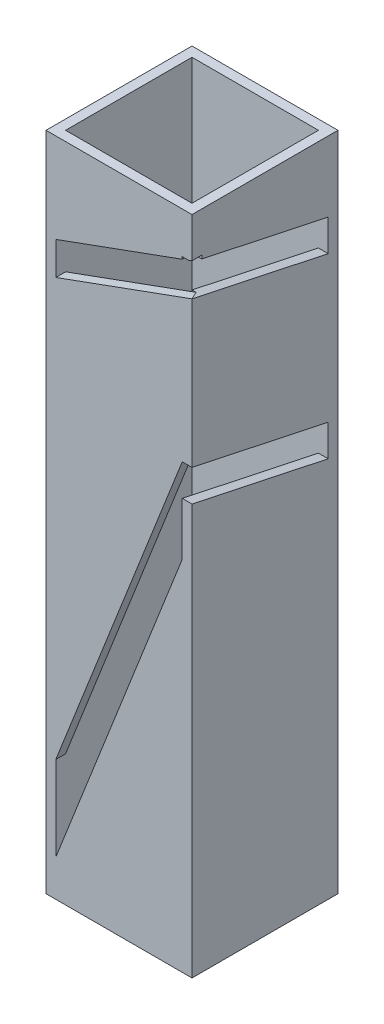
from build123d import *

# Parameters (mm, degrees)
SKETCH1_W           = 44.862
SKETCH1_H           = 44.862
SKETCH1_W_2         = 38.862
SKETCH1_H_2         = 38.862
BOSS_EXTRUDE1_DEPTH = 203.2
X_FACE_CUT_DEPTH    = 3
Y_FACE_DEPTH        = 3


with BuildPart() as part:
    # Sketch1 → Boss-Extrude1 (new body)
    with BuildSketch(Plane(origin=(0, 0, 0), x_dir=(1, 0, 0), z_dir=(0, 1, 0))):
        Rectangle(SKETCH1_W, SKETCH1_H)
        Rectangle(SKETCH1_W_2, SKETCH1_H_2, mode=Mode.SUBTRACT)
    extrude(amount=BOSS_EXTRUDE1_DEPTH)

    # Sketch3 → X Face Cut (cut)
    with BuildSketch(Plane(origin=(22.431, 0, 0), x_dir=(0, 0, -1), z_dir=(1, 0, 0))):
        Polygon((-22.431, 190.5), (19.431, 181.601957215), (19.431, 171.864163049), (-22.431, 180.762205834), align=None)
        Polygon((-22.431, 126.160248619), (19.431, 117.262205834), (19.431, 127), (-22.431, 135.898042785), align=None)
    extrude(amount=-X_FACE_CUT_DEPTH, mode=Mode.SUBTRACT)

    # Sketch4 → Y Face (cut)
    with BuildSketch(Plane.XY.offset(22.431)):
        Polygon((22.431, 180.762205834), (-19.431, 165.525683887), (-19.431, 175.66197717), (22.431, 190.898499117), align=None)
        Polygon((19.431, 109.909043825), (-19.431, 11.252109304), (-19.431, 37.241108263), (19.431, 135.898042785), align=None)
    extrude(amount=-Y_FACE_DEPTH, mode=Mode.SUBTRACT)


solid = part.part
